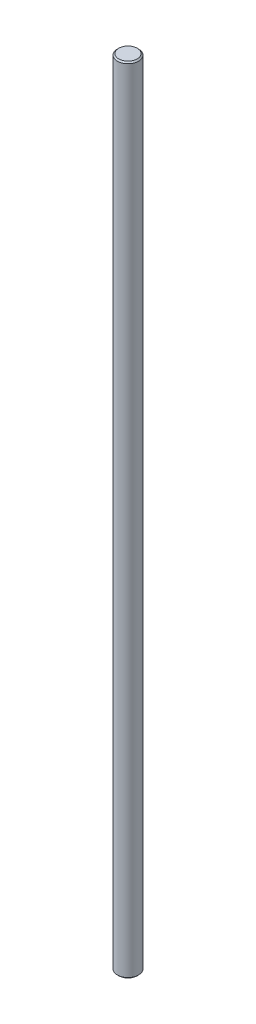
from build123d import *

# Parameters (mm, degrees)
SKETCH1_R           = 4
BOSS_EXTRUDE1_DEPTH = 300
CHAMFER1_SIZE       = 0.5


with BuildPart() as part:
    # Sketch1 → Boss-Extrude1 (new body)
    with BuildSketch(Plane(origin=(0, 0, 0), x_dir=(1, 0, 0), z_dir=(0, 1, 0))):
        Circle(SKETCH1_R)
    extrude(amount=BOSS_EXTRUDE1_DEPTH)

    # Chamfer1
    chamfer1_edges = [part.edges().sort_by_distance(p)[0] for p in [
        (-4, 0, 0),
        (-4, 300, 0),
    ]]
    chamfer(chamfer1_edges, length=CHAMFER1_SIZE)


solid = part.part
